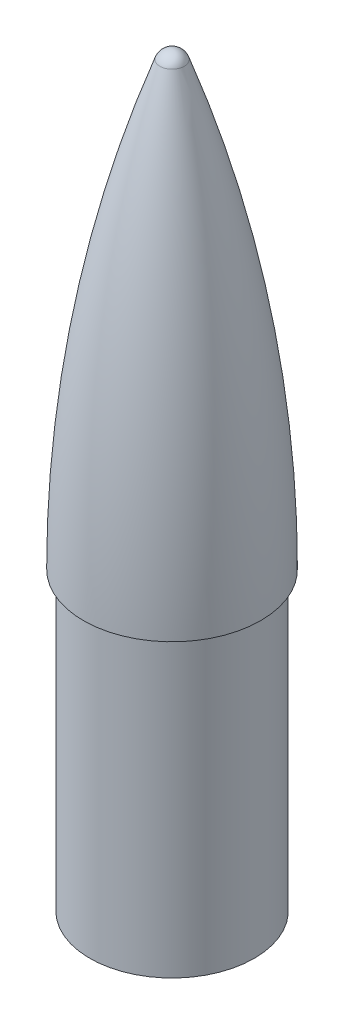
from build123d import *

# Parameters (mm, degrees)
SKETCH2_R          = 2.35
CUT_EXTRUDE1_DEPTH = 10


with BuildPart() as part:
    # Sketch1 → Revolve3 (revolve)
    with BuildSketch(Plane.XY):
        with BuildLine():
            Line((-19.055, 0), (-20.555, 0))
            ThreePointArc((-20.555, 0), (-16.08987064, 51.964475913), (-2.825386961, 102.405506928))
            ThreePointArc((-2.825386961, 102.405506928), (-1.728341267, 103.849057861), (0, 104.396949286))
            Line((0, 104.396949286), (0, 102.396949286))
            Line((0, 102.396949286), (0, 71.445540784))
            Line((0, 71.445540784), (-10, 71.445540784))
            Line((-10, 71.445540784), (-10, -68.554459216))
            Line((-10, -68.554459216), (-17.055, -68.554459216))
            Line((-17.055, -68.554459216), (-19.055, -68.554459216))
            Line((-19.055, -68.554459216), (-19.055, 0))
        make_face()
    revolve(axis=Axis((0, 102.396949286, 0), (0, 1, 0)))

    # Sketch2 → Cut-Extrude1 (cut)
    with BuildSketch(Plane.XZ.offset(68.554459216)):
        with Locations((0, -14.055)):
            Circle(SKETCH2_R)
        with Locations((0, 14.055)):
            Circle(SKETCH2_R)
    extrude(amount=-CUT_EXTRUDE1_DEPTH, mode=Mode.SUBTRACT)


solid = part.part
